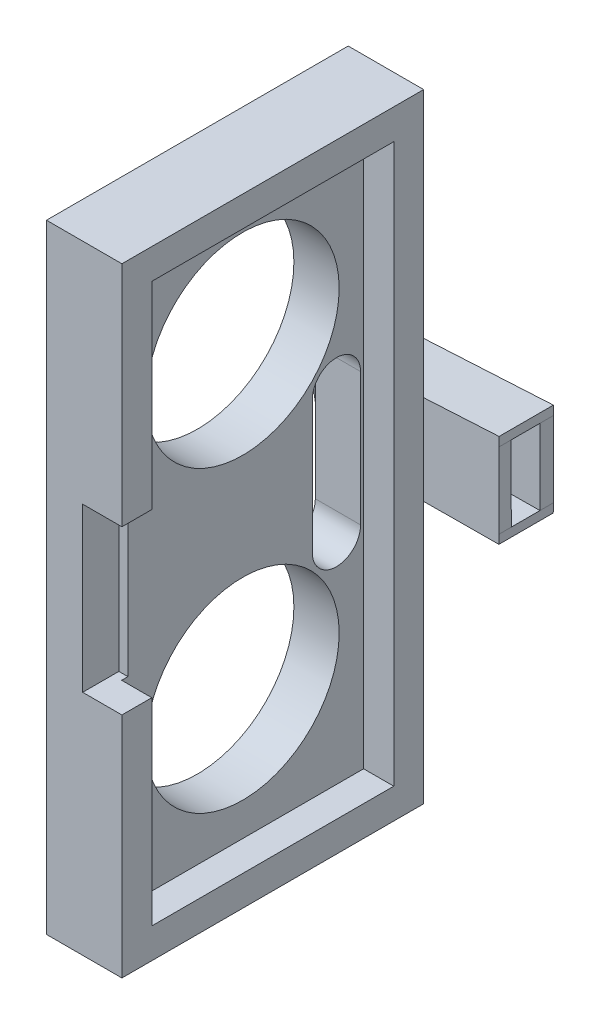
from build123d import *

# Parameters (mm, degrees)
BOSS_EXTRUDE1_DEPTH      = 1.524
BOSS_EXTRUDE1_DEPTH_BACK = 3.048
BOSS_EXTRUDE2_DEPTH      = 1.016
BOSS_EXTRUDE3_DEPTH      = 1.143
SKETCH4_W                = 6.35
SKETCH4_H                = 52.07
BOSS_EXTRUDE4_DEPTH      = 25.4
SKETCH5_W                = 20.3708
SKETCH5_H                = 46.99
CUT_EXTRUDE1_DEPTH       = 2.54
SKETCH6_R                = 8.128
CUT_EXTRUDE2_DEPTH       = 7.695152554
SKETCH7_W                = 3.302
SKETCH7_H                = 13.716
CUT_EXTRUDE3_DEPTH       = 3.048
CUT_EXTRUDE4_DEPTH       = 3.81


with BuildPart() as part:
    # Sketch1 → Boss-Extrude1 (new body, two sides)
    with BuildSketch(Plane.XY) as boss_extrude1_sk:
        with BuildLine():
            Line((-2.221121967, 3.920099398), (-14.159121967, 3.267778706))
            ThreePointArc((-14.159121967, 3.267778706), (-17.805238677, -0.371570093), (-14.172670351, -4.024442128))
            Line((-14.172670351, -4.024442128), (-2.234670351, -3.953900602))
            Line((-2.234670351, -3.953900602), (-2.209072203, -3.191900602))
            Line((-2.209072203, -3.191900602), (-14.147072203, -3.262442128))
            ThreePointArc((-14.147072203, -3.262442128), (-17.043238677, -0.384369192), (-14.159121967, 2.505778706))
            Line((-14.159121967, 2.505778706), (-2.221121967, 3.158099398))
            Line((-2.221121967, 3.158099398), (-2.221121967, 3.920099398))
        make_face()
    extrude(amount=BOSS_EXTRUDE1_DEPTH)
    extrude(boss_extrude1_sk.sketch, amount=-BOSS_EXTRUDE1_DEPTH_BACK)

    # Sketch2 → Boss-Extrude2 (add)
    with BuildSketch(Plane.XY.offset(1.524)):
        with BuildLine():
            Line((-2.209072203, -3.191900602), (-2.221121967, 3.158099398))
            Line((-2.221121967, 3.158099398), (-14.159121967, 2.505778706))
            ThreePointArc((-14.159121967, 2.505778706), (-17.043238677, -0.384369192), (-14.147072203, -3.262442128))
            Line((-14.147072203, -3.262442128), (-2.209072203, -3.191900602))
        make_face()
    extrude(amount=-BOSS_EXTRUDE2_DEPTH)

    # Sketch3 → Boss-Extrude3 (add)
    with BuildSketch(Plane(origin=(0, 0, -3.048), x_dir=(-1, 0, 0), z_dir=(0, 0, -1))):
        with BuildLine():
            Line((14.159121967, 2.505778706), (2.221121967, 3.158099398))
            Line((2.221121967, 3.158099398), (2.209072203, -3.191900602))
            Line((2.209072203, -3.191900602), (14.147072203, -3.262442128))
            ThreePointArc((14.147072203, -3.262442128), (17.043238677, -0.384369192), (14.159121967, 2.505778706))
        make_face()
    extrude(amount=-BOSS_EXTRUDE3_DEPTH)

    # Sketch4 → Boss-Extrude4 (add)
    with BuildSketch(Plane.XY.offset(1.524)):
        with Locations((-11.745092416, 0)):
            Rectangle(SKETCH4_W, SKETCH4_H)
    extrude(amount=BOSS_EXTRUDE4_DEPTH)

    # Sketch5 → Cut-Extrude1 (cut)
    with BuildSketch(Plane(origin=(-8.570092416, 0, 0), x_dir=(0, 0, -1), z_dir=(1, 0, 0))):
        with Locations((-14.224, 0)):
            Rectangle(SKETCH5_W, SKETCH5_H)
    extrude(amount=-CUT_EXTRUDE1_DEPTH, mode=Mode.SUBTRACT)

    # Sketch6 → Cut-Extrude2 (cut, through all)
    with BuildSketch(Plane(origin=(-11.110092416, 0, 0), x_dir=(0, 0, -1), z_dir=(1, 0, 0))):
        with Locations((-14.224, -12.573)):
            Circle(SKETCH6_R)
        with Locations((-14.224, 12.573)):
            Circle(SKETCH6_R)
    extrude(amount=-CUT_EXTRUDE2_DEPTH, mode=Mode.SUBTRACT)

    # Sketch7 → Cut-Extrude3 (cut)
    with BuildSketch(Plane.XY.offset(26.924)):
        with Locations((-10.221092416, 0)):
            Rectangle(SKETCH7_W, SKETCH7_H)
    extrude(amount=-CUT_EXTRUDE3_DEPTH, mode=Mode.SUBTRACT)

    # Sketch8 → Cut-Extrude4 (cut)
    with BuildSketch(Plane(origin=(-11.110092416, 0, 0), x_dir=(0, 0, -1), z_dir=(1, 0, 0))):
        with BuildLine():
            Line((-8.3566, -5.588), (-8.3566, 5.588))
            ThreePointArc((-8.3566, 5.588), (-6.3246, 7.62), (-4.2926, 5.588))
            Line((-4.2926, 5.588), (-4.2926, -5.588))
            ThreePointArc((-4.2926, -5.588), (-6.3246, -7.62), (-8.3566, -5.588))
        make_face()
    extrude(amount=-CUT_EXTRUDE4_DEPTH, mode=Mode.SUBTRACT)


solid = part.part
